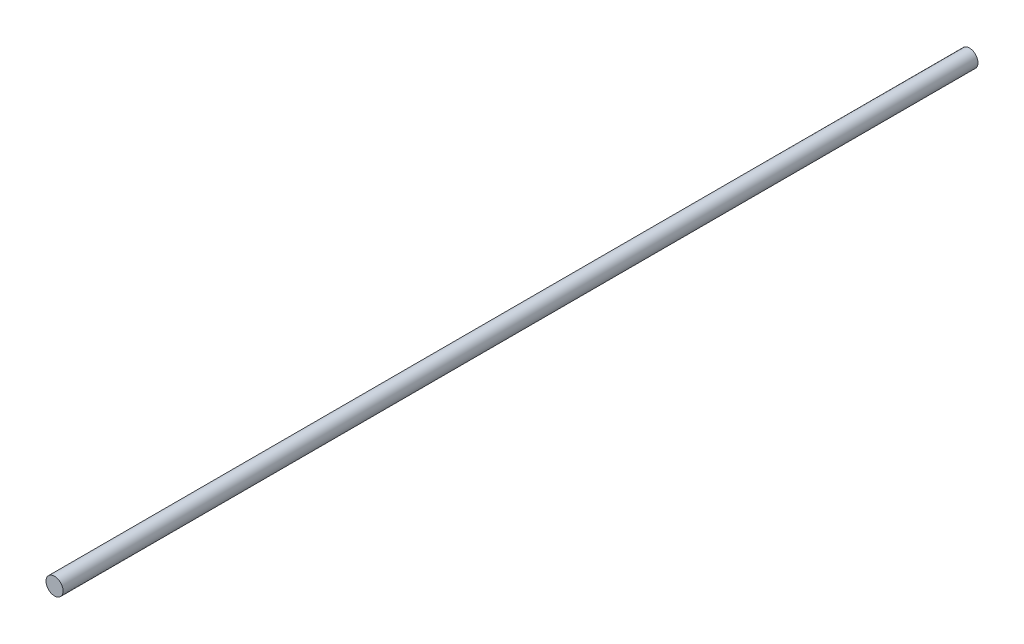
from build123d import *

# Parameters (mm, degrees)
SKETCH1_R           = 4
BOSS_EXTRUDE1_DEPTH = 428


with BuildPart() as part:
    # Sketch1 → Boss-Extrude1 (new body)
    with BuildSketch(Plane.XY):
        Circle(SKETCH1_R)
    extrude(amount=BOSS_EXTRUDE1_DEPTH)


solid = part.part
